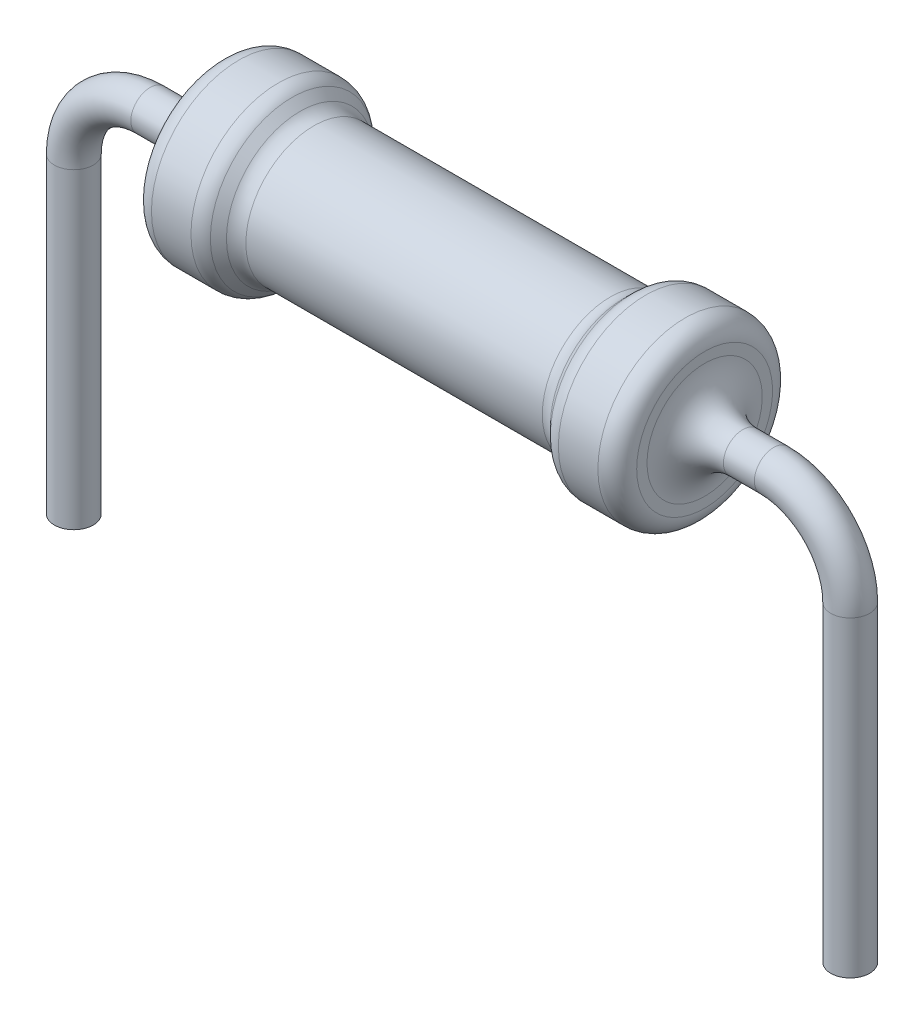
from build123d import *

# Parameters (mm, degrees)
SKETCH3_R = 0.254
FILLET1_R = 0.5


with BuildPart() as part:
    # Sketch1 → Revolve1 (revolve)
    with BuildSketch(Plane.XY):
        with BuildLine():
            Line((1.93961936, 0.889), (-1.93961936, 0.889))
            ThreePointArc((-1.93961936, 0.889), (-2.036820952, 0.908334599), (-2.119224483, 0.963394878))
            Line((-2.119224483, 0.963394878), (-2.224434728, 1.068605122))
            ThreePointArc((-2.224434728, 1.068605122), (-2.306838258, 1.123665401), (-2.40403985, 1.143))
            Line((-2.40403985, 1.143), (-2.921, 1.143))
            ThreePointArc((-2.921, 1.143), (-3.100605122, 1.068605122), (-3.175, 0.889))
            Line((-3.175, 0.889), (-3.175, 0))
            Line((-3.175, 0), (3.175, 0))
            Line((3.175, 0), (3.175, 0.889))
            ThreePointArc((3.175, 0.889), (3.100605122, 1.068605122), (2.921, 1.143))
            Line((2.921, 1.143), (2.40403985, 1.143))
            ThreePointArc((2.40403985, 1.143), (2.306838258, 1.123665401), (2.224434728, 1.068605122))
            Line((2.224434728, 1.068605122), (2.119224483, 0.963394878))
            ThreePointArc((2.119224483, 0.963394878), (2.036820952, 0.908334599), (1.93961936, 0.889))
        make_face()
    revolve(axis=Axis((-13.051535928, 0, 0), (1, 0, 0)))

    # Sweep1: sweep along a path in Sketch2
    with BuildLine(Plane.XY) as sweep1_path:
        Line((0, 0), (4.08, 0))
        ThreePointArc((4.08, 0), (4.787106781, -0.292893219), (5.08, -1))
        Line((5.08, -1), (5.08, -5.08))
    # Sketch3 → Sweep1 (sweep)
    with BuildSketch(Plane(origin=(0, 0, 0), x_dir=(0, 0, -1), z_dir=(1, 0, 0))):
        Circle(SKETCH3_R)
    sweep1 = sweep(path=sweep1_path.line)

    # Mirror1: Sweep1 across plane
    add(sweep1.mirror(Plane(origin=(0, 0, 0), x_dir=(0, 0, 1), z_dir=(1, 0, 0))))

    # Fillet1
    fillet1_edges = [part.edges().sort_by_distance(p)[0] for p in [
        (3.175, 0, 0.254),
        (-3.175, 0, 0.254),
    ]]
    fillet(fillet1_edges, radius=FILLET1_R)


solid = part.part
